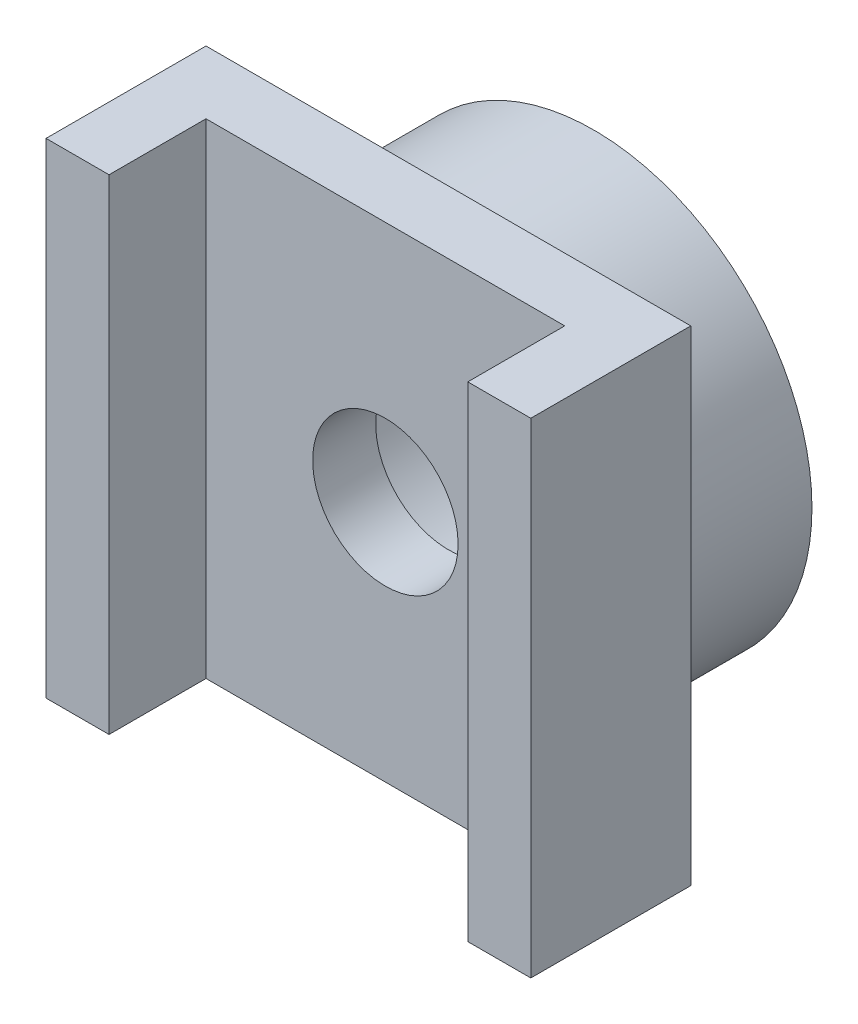
from build123d import *

# Parameters (mm, degrees)
SKETCH1_R              = 4.5
SKETCH1_R_2            = 2.85
MAIN_AXIS_DEPTH        = 3
SKETCH2_W              = 10
SKETCH2_H              = 10
SKETCH2_R              = 1.5
BASE_OF_RECTAGLE_DEPTH = 1.3
SKETCH3_W              = 1.3
SKETCH3_H              = 10
PULLEY_SUPPORT_DEPTH   = 2


with BuildPart() as part:
    # Sketch1 → Main Axis (new body)
    with BuildSketch(Plane.XY):
        Circle(SKETCH1_R)
        Circle(SKETCH1_R_2, mode=Mode.SUBTRACT)
    extrude(amount=MAIN_AXIS_DEPTH)

    # Sketch2 → Base of Rectagle (add)
    with BuildSketch(Plane.XY.offset(3)):
        Rectangle(SKETCH2_W, SKETCH2_H)
        Circle(SKETCH2_R, mode=Mode.SUBTRACT)
    extrude(amount=BASE_OF_RECTAGLE_DEPTH)

    # Sketch3 → Pulley Support (add)
    with BuildSketch(Plane.XY.offset(4.3)):
        with Locations((-4.35, 0)):
            Rectangle(SKETCH3_W, SKETCH3_H)
        with Locations((4.35, 0)):
            Rectangle(SKETCH3_W, SKETCH3_H)
    extrude(amount=PULLEY_SUPPORT_DEPTH)


solid = part.part
